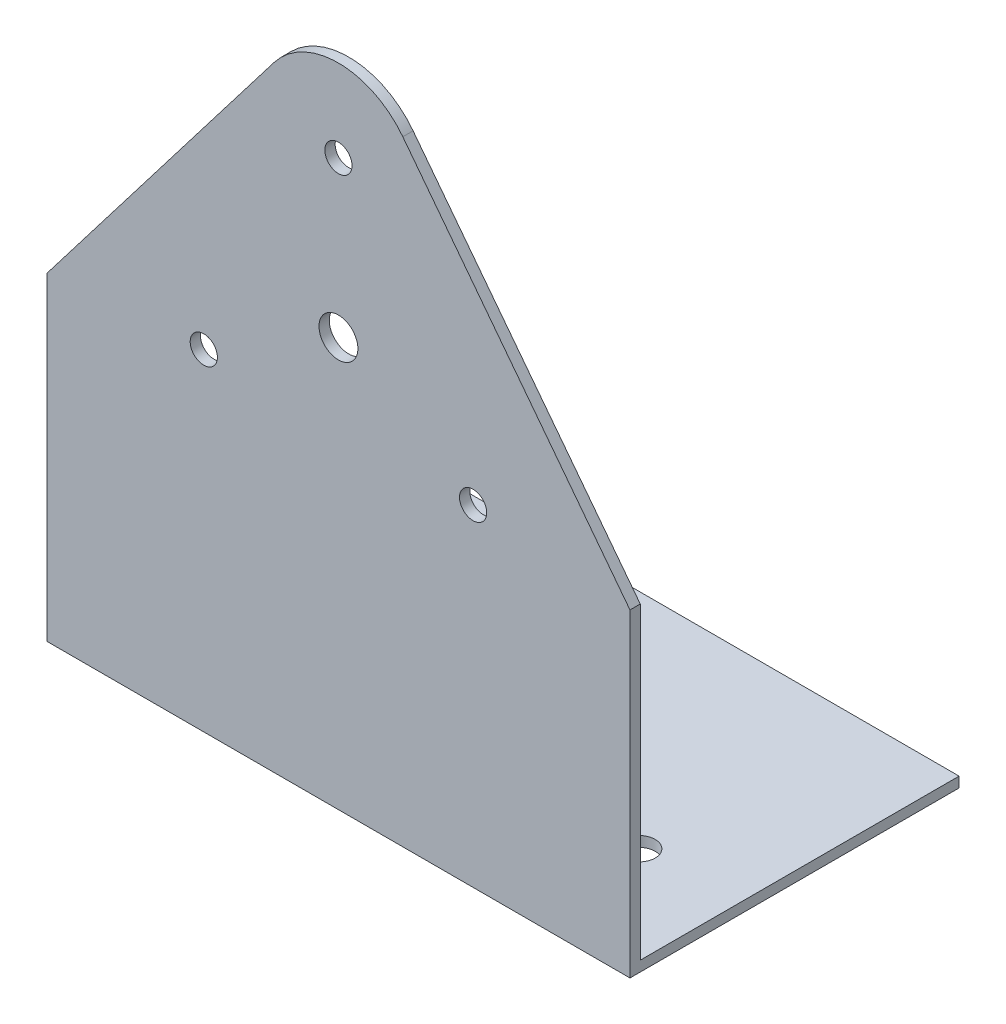
from build123d import *

# Parameters (mm, degrees)
BOSS_EXTRUDE1_DEPTH = 90
CUT_EXTRUDE1_DEPTH  = 51.8
SKETCH3_R           = 2.1
SKETCH3_R_2         = 3
CUT_EXTRUDE2_DEPTH  = 51.8
SKETCH4_R           = 2.5
CUT_EXTRUDE3_DEPTH  = 100.821221194


with BuildPart() as part:
    # Sketch1 → Boss-Extrude1 (new body)
    with BuildSketch(Plane(origin=(0, 0, 0), x_dir=(0, 0, -1), z_dir=(1, 0, 0))):
        Polygon((0, 0), (0, 100), (1.5875, 100), (1.5875, 1.5875), (50.8, 1.5875), (50.8, 0), align=None)
    extrude(amount=BOSS_EXTRUDE1_DEPTH)

    # Sketch2 → Cut-Extrude1 (cut, through all)
    with BuildSketch(Plane.XY):
        with BuildLine():
            Line((35.064378218, 94.92), (0, 49.2))
            Line((0, 49.2), (0, 100))
            Line((0, 100), (90, 100))
            Line((90, 100), (90, 49.2))
            Line((90, 49.2), (54.935621782, 94.92))
            ThreePointArc((54.935621782, 94.92), (45, 99.821221194), (35.064378218, 94.92))
        make_face()
    extrude(amount=-CUT_EXTRUDE1_DEPTH, mode=Mode.SUBTRACT)

    # Sketch3 → Cut-Extrude2 (cut, through all)
    with BuildSketch(Plane.XY):
        with Locations((45, 87.121221194)):
            Circle(SKETCH3_R)
        with Locations((65.784609691, 51.121221194)):
            Circle(SKETCH3_R)
        with Locations((24.215390309, 51.121221194)):
            Circle(SKETCH3_R)
        with Locations((45, 63.121221194)):
            Circle(SKETCH3_R_2)
    extrude(amount=-CUT_EXTRUDE2_DEPTH, mode=Mode.SUBTRACT)

    # Sketch4 → Cut-Extrude3 (cut, through all)
    with BuildSketch(Plane.XZ):
        with Locations((15, -16.3875)):
            Circle(SKETCH4_R)
        with Locations((75, -16.3875)):
            Circle(SKETCH4_R)
    extrude(amount=-CUT_EXTRUDE3_DEPTH, mode=Mode.SUBTRACT)


solid = part.part
